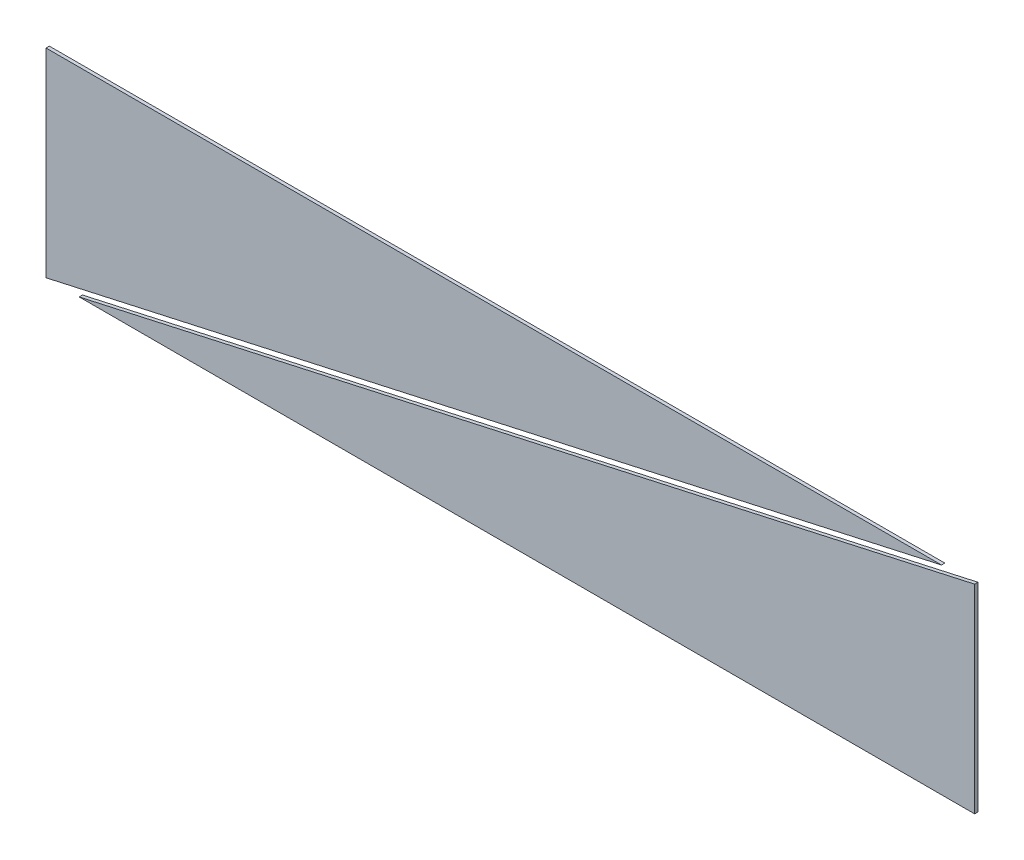
from build123d import *

# Parameters (mm, degrees)
BOSS_EXTRUDE1_DEPTH   = 0.25
BOSS_EXTRUDE1_2_DEPTH = 0.25


with BuildPart() as part:
    # Sketch11 → Boss-Extrude1 (new body)
    with BuildSketch(Plane(origin=(0, -5, 0), x_dir=(1, 0, 0), z_dir=(0, 0, 1))):
        Polygon((-35, 12.5), (32.5, 12.5), (-35, -2.5), align=None)
    extrude(amount=BOSS_EXTRUDE1_DEPTH)


with BuildPart() as body_2:
    # Sketch11 → Boss-Extrude1 2 (new body)
    with BuildSketch(Plane(origin=(0, -5, 0), x_dir=(1, 0, 0), z_dir=(0, 0, 1))):
        Polygon((-32.5, -2.5), (35, -2.5), (35, 12.5), align=None)
    extrude(amount=BOSS_EXTRUDE1_2_DEPTH)


solid = Compound([part.part, body_2.part])
